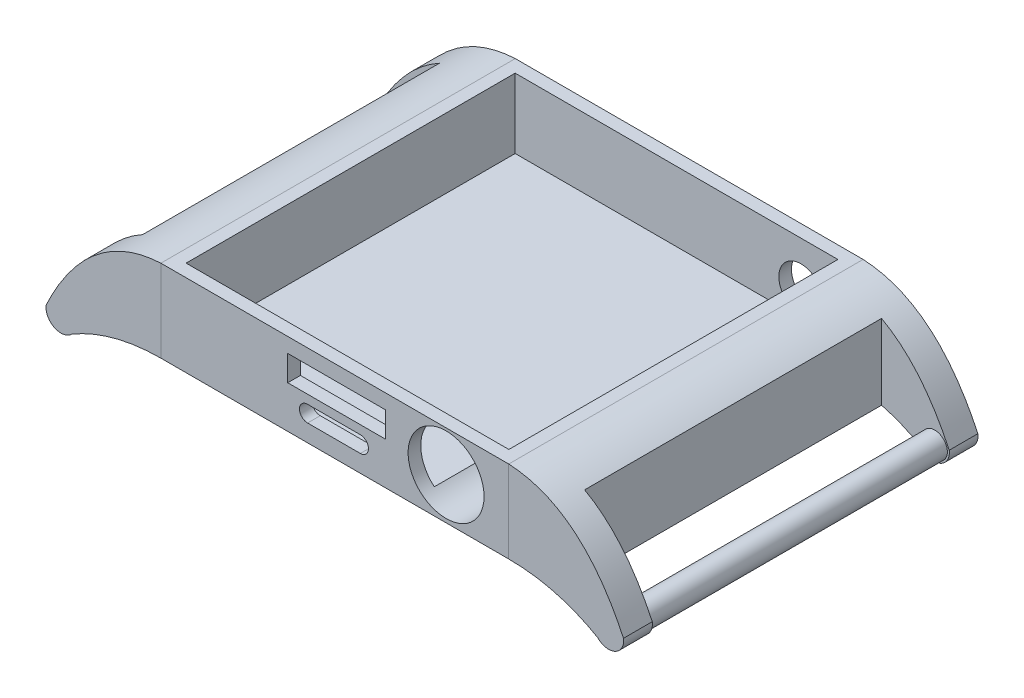
from build123d import *

# Parameters (mm, degrees)
SKETCH1_W               = 54.97
SKETCH1_H               = 56
BOSS_EXTRUDE1_DEPTH     = 13
SKETCH2_W               = 51
SKETCH2_H               = 52
CUT_EXTRUDE1_DEPTH      = 11
SKETCH3_R               = 6
CUT_EXTRUDE2_DEPTH      = 11
SKETCH4_W               = 15.449301527
SKETCH4_H               = 4.016818397
CUT_EXTRUDE3_DEPTH      = 11
SKETCH5_R               = 3.5
CUT_EXTRUDE4_DEPTH      = 11
BOSS_EXTRUDE2_DEPTH     = 56
SKETCH7_W               = 11.055643201
SKETCH7_H               = 46.925063364
CUT_EXTRUDE5_DEPTH      = 11
CUT_EXTRUDE5_DEPTH_BACK = 11
SKETCH8_R               = 2
BOSS_EXTRUDE3_DEPTH     = 46.925063


with BuildPart() as part:
    # Sketch1 → Boss-Extrude1 (new body)
    with BuildSketch(Plane(origin=(0, 0, 0), x_dir=(1, 0, 0), z_dir=(0, 1, 0))):
        Rectangle(SKETCH1_W, SKETCH1_H)
    extrude(amount=BOSS_EXTRUDE1_DEPTH)

    # Sketch2 → Cut-Extrude1 (cut)
    with BuildSketch(Plane(origin=(0, 13, 0), x_dir=(1, 0, 0), z_dir=(0, 1, 0))):
        Rectangle(SKETCH2_W, SKETCH2_H)
    extrude(amount=-CUT_EXTRUDE1_DEPTH, mode=Mode.SUBTRACT)

    # Sketch3 → Cut-Extrude2 (cut)
    with BuildSketch(Plane.XY.offset(28)):
        with Locations((17.58480672, 6.590072484)):
            Circle(SKETCH3_R)
        with BuildLine():
            Line((4.037012251, 2.721252654), (-4.302987749, 2.721252654))
            ThreePointArc((-4.302987749, 2.721252654), (-5.582987749, 4.001252654), (-4.302987749, 5.281252654))
            Line((-4.302987749, 5.281252654), (4.037012251, 5.281252654))
            ThreePointArc((4.037012251, 5.281252654), (5.317012251, 4.001252654), (4.037012251, 2.721252654))
        make_face()
    extrude(amount=-CUT_EXTRUDE2_DEPTH, mode=Mode.SUBTRACT)

    # Sketch4 → Cut-Extrude3 (cut)
    with BuildSketch(Plane.XY.offset(28)):
        with Locations((0.285779877, 8.667738861)):
            Rectangle(SKETCH4_W, SKETCH4_H)
    extrude(amount=-CUT_EXTRUDE3_DEPTH, mode=Mode.SUBTRACT)

    # Sketch5 → Cut-Extrude4 (cut)
    with BuildSketch(Plane(origin=(0, 0, -28), x_dir=(-1, 0, 0), z_dir=(0, 0, -1))):
        with Locations((-19.663814967, 5.987097456)):
            Circle(SKETCH5_R)
    extrude(amount=-CUT_EXTRUDE4_DEPTH, mode=Mode.SUBTRACT)


with BuildPart() as body_2:
    # Sketch6 → Boss-Extrude2 (new body)
    with BuildSketch(Plane(origin=(0, 0, -28), x_dir=(-1, 0, 0), z_dir=(0, 0, -1))):
        with BuildLine():
            Line((-27.485, 0), (-27.485, 13))
            add(Edge.make_bspline(
                [(-45.618050055, -1.78397783), (-38.965723797, 12.38963767), (-27.485, 13)],
                knots=[0, 0, 0, 0.917429215, 0.917429215, 0.917429215], degree=2))
            ThreePointArc((-45.618050055, -1.78397783), (-44.30948041, -4.228252554), (-41.578017137, -3.75291917))
            add(Edge.make_bspline(
                [(-27.485, 0), (-35.193013177, -0.027010038), (-41.578017137, -3.75291917)],
                knots=[0, 0, 0, 1, 1, 1], degree=2))
        make_face()
    extrude(amount=-BOSS_EXTRUDE2_DEPTH)

    # Sketch7 → Cut-Extrude5 (cut, two sides)
    with BuildSketch(Plane(origin=(0, 0, 0), x_dir=(1, 0, 0), z_dir=(0, 1, 0))) as cut_extrude5_sk:
        with Locations((40.45624055, 0.011076051)):
            Rectangle(SKETCH7_W, SKETCH7_H)
    extrude(amount=CUT_EXTRUDE5_DEPTH, mode=Mode.SUBTRACT)
    extrude(cut_extrude5_sk.sketch, amount=-CUT_EXTRUDE5_DEPTH_BACK, mode=Mode.SUBTRACT)


with BuildPart() as body_3:
    # Sketch8 → Boss-Extrude3 (new body)
    with BuildSketch(Plane.XY.offset(-23.473607733)):
        with Locations((43.326467318, -2.162635088)):
            Circle(SKETCH8_R)
    extrude(amount=BOSS_EXTRUDE3_DEPTH)


with BuildPart() as body_4:
    # Mirror2: mirrored copy
    add(body_2.part.mirror(Plane(origin=(0, 0, 0), x_dir=(0, 0, 1), z_dir=(1, 0, 0))))


with BuildPart() as body_5:
    # Mirror2 2: mirrored copy
    add(body_3.part.mirror(Plane(origin=(0, 0, 0), x_dir=(0, 0, 1), z_dir=(1, 0, 0))))


solid = Compound([part.part, body_2.part, body_3.part, body_4.part, body_5.part])
